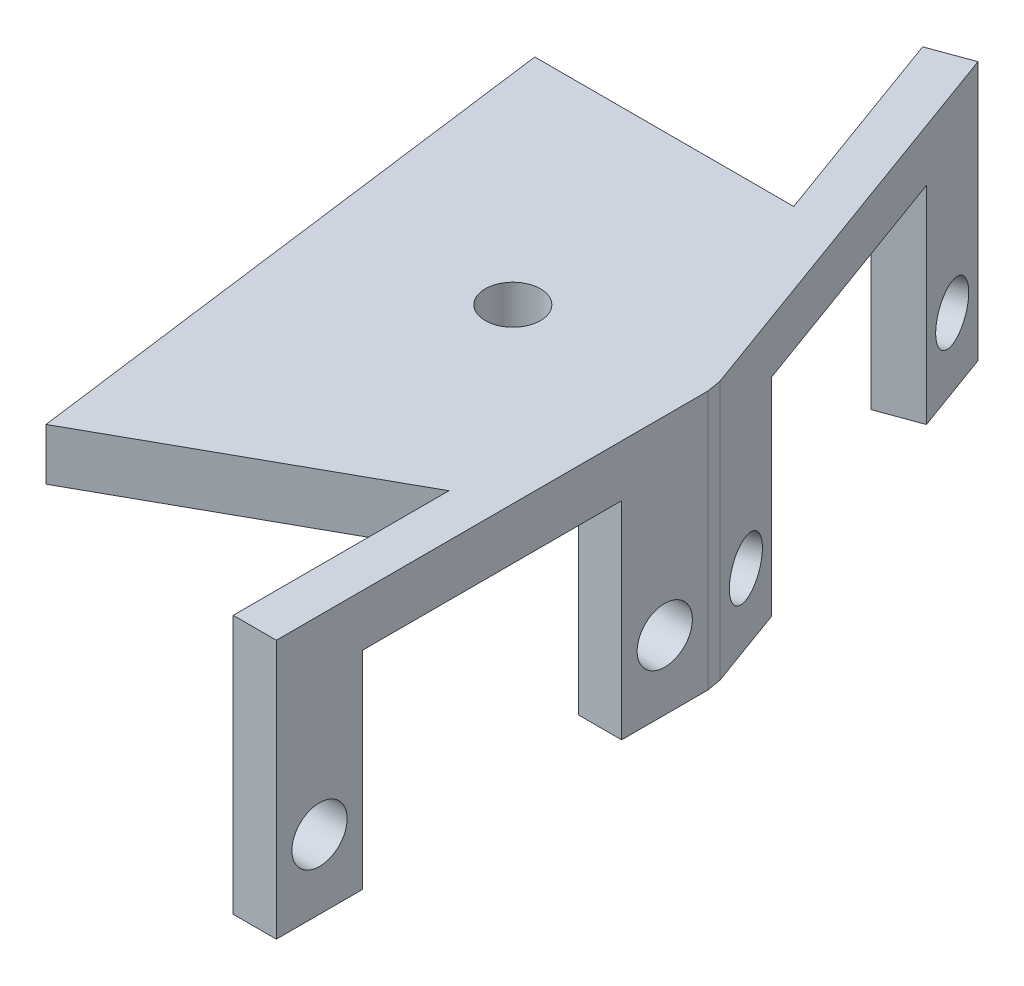
from build123d import *

# Parameters (mm, degrees)
BOSS_EXTRUDE1_DEPTH = 15
SKETCH5_R           = 1.6
SKETCH5_W           = 15
SKETCH5_H           = 12
CUT_EXTRUDE4_DEPTH  = 15
SKETCH8_R           = 1.6
SKETCH8_W           = 15
SKETCH8_H           = 12.119225193
CUT_EXTRUDE5_DEPTH  = 15
SKETCH6_R           = 1.6
BOSS_EXTRUDE8_DEPTH = 3


with BuildPart() as part:
    # Sketch1 → Boss-Extrude1 (new body)
    with BuildSketch(Plane(origin=(0, 0, 0), x_dir=(1, 0, 0), z_dir=(0, 1, 0))):
        Polygon((-0.46984631, -0.171010072), (-0.46984631, -25.171010072), (-2.96984631, -25.171010072), (-2.96984631, -0.171010072), (-11.520349894, 23.321305448), (-9.171118342, 24.176355806), (-0.620614758, 0.684040287), align=None)
    extrude(amount=-BOSS_EXTRUDE1_DEPTH)

    # Sketch5 → Cut-Extrude4 (cut)
    with BuildSketch(Plane(origin=(-0.46984631, 0, 0), x_dir=(0, 0, -1), z_dir=(1, 0, 0))):
        with Locations((-22.671010072, -11)):
            Circle(SKETCH5_R)
        with Locations((-2.671010072, -11)):
            Circle(SKETCH5_R)
        with Locations((-12.671010072, -9)):
            Rectangle(SKETCH5_W, SKETCH5_H)
    extrude(amount=-CUT_EXTRUDE4_DEPTH, mode=Mode.SUBTRACT)

    # Sketch8 → Cut-Extrude5 (cut)
    with BuildSketch(Plane(origin=(-0.328170312, 0, 0.119444225), x_dir=(-0.342020143, 0, -0.939692621), z_dir=(0.939692621, 0, -0.342020143))):
        with Locations((3.355050358, -11)):
            Circle(SKETCH8_R)
        with Locations((23.355050358, -11)):
            Circle(SKETCH8_R)
        with Locations((13.355050358, -9.059612596)):
            Rectangle(SKETCH8_W, SKETCH8_H)
    extrude(amount=-CUT_EXTRUDE5_DEPTH, mode=Mode.SUBTRACT)

    # Sketch6 → Boss-Extrude8 (add)
    with BuildSketch(Plane(origin=(0, 0, 0), x_dir=(1, 0, 0), z_dir=(0, 1, 0))):
        Polygon((-7.245098102, 11.575147688), (-22.245098102, 11.575147688), (-17.96984631, -21.01652559), (-2.96984631, -12.671010072), (-0.46984631, -0.171010072), (-0.620614758, 0.684040287), align=None)
        with Locations((-10.452336242, -1.490374929)):
            Circle(SKETCH6_R, mode=Mode.SUBTRACT)
    extrude(amount=-BOSS_EXTRUDE8_DEPTH)


solid = part.part
